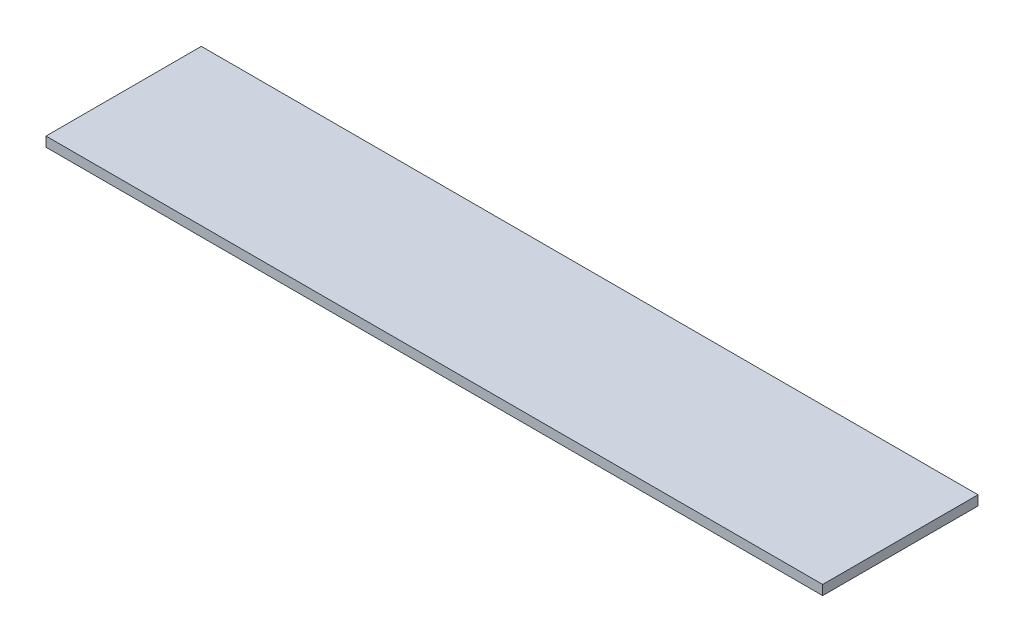
from build123d import *

# Parameters (mm, degrees)
SKETCH2_W           = 127
SKETCH2_H           = 25.4
BOSS_EXTRUDE1_DEPTH = 1.5875


with BuildPart() as part:
    # Sketch2 → Boss-Extrude1 (new body)
    with BuildSketch(Plane(origin=(0, 0, 0), x_dir=(1, 0, 0), z_dir=(0, 1, 0))):
        with Locations((63.5, 12.7)):
            Rectangle(SKETCH2_W, SKETCH2_H)
    extrude(amount=BOSS_EXTRUDE1_DEPTH)


solid = part.part
